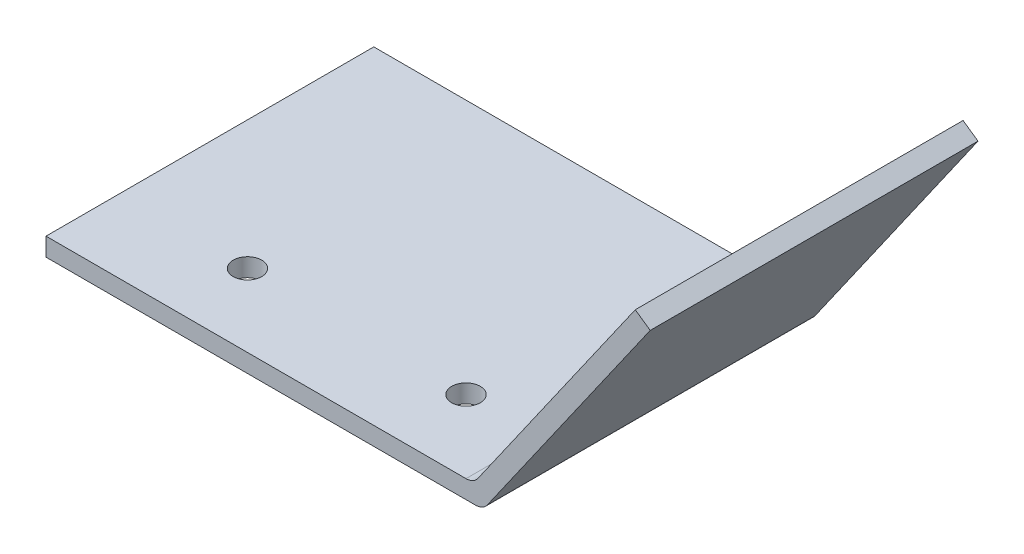
from build123d import *

# Parameters (mm, degrees)
BOSS_EXTRUDE1_DEPTH = 28.575
FILLET1_R           = 2.54
FILLET2_R           = 2.54
SKETCH2_R           = 2.4892
CUT_EXTRUDE1_DEPTH  = 4.175


with BuildPart() as part:
    # Sketch1 → Boss-Extrude1 (new body, symmetric)
    with BuildSketch(Plane.XY):
        Polygon((76.2, 0), (73.599192259, 1.821105185), (74.547199614, 3.175), (0, 3.175), (0, 0), align=None)
        Polygon((76.2, 3.175), (76.2, 0), (105.337682967, 41.61292385), (102.736875226, 43.434029035), (74.547199614, 3.175), align=None)
        Polygon((74.547199614, 3.175), (73.599192259, 1.821105185), (76.2, 0), (76.2, 3.175), align=None)
    extrude(amount=BOSS_EXTRUDE1_DEPTH, both=True)

    # Fillet1
    fillet1_edges = [part.edges().sort_by_distance(p)[0] for p in [
        (74.547199614, 3.175, 0),
    ]]
    fillet(fillet1_edges, radius=FILLET1_R)

    # Fillet2
    fillet2_edges = [part.edges().sort_by_distance(p)[0] for p in [
        (76.2, 0, 0),
    ]]
    fillet(fillet2_edges, radius=FILLET2_R)

    # Sketch2 → Cut-Extrude1 (cut, through all)
    with BuildSketch(Plane(origin=(0, 3.175, 0), x_dir=(1, 0, 0), z_dir=(0, 1, 0))):
        with Locations((60.524959306, -15.875)):
            Circle(SKETCH2_R)
        with Locations((22.424959306, -15.875)):
            Circle(SKETCH2_R)
    extrude(amount=-CUT_EXTRUDE1_DEPTH, mode=Mode.SUBTRACT)


solid = part.part
